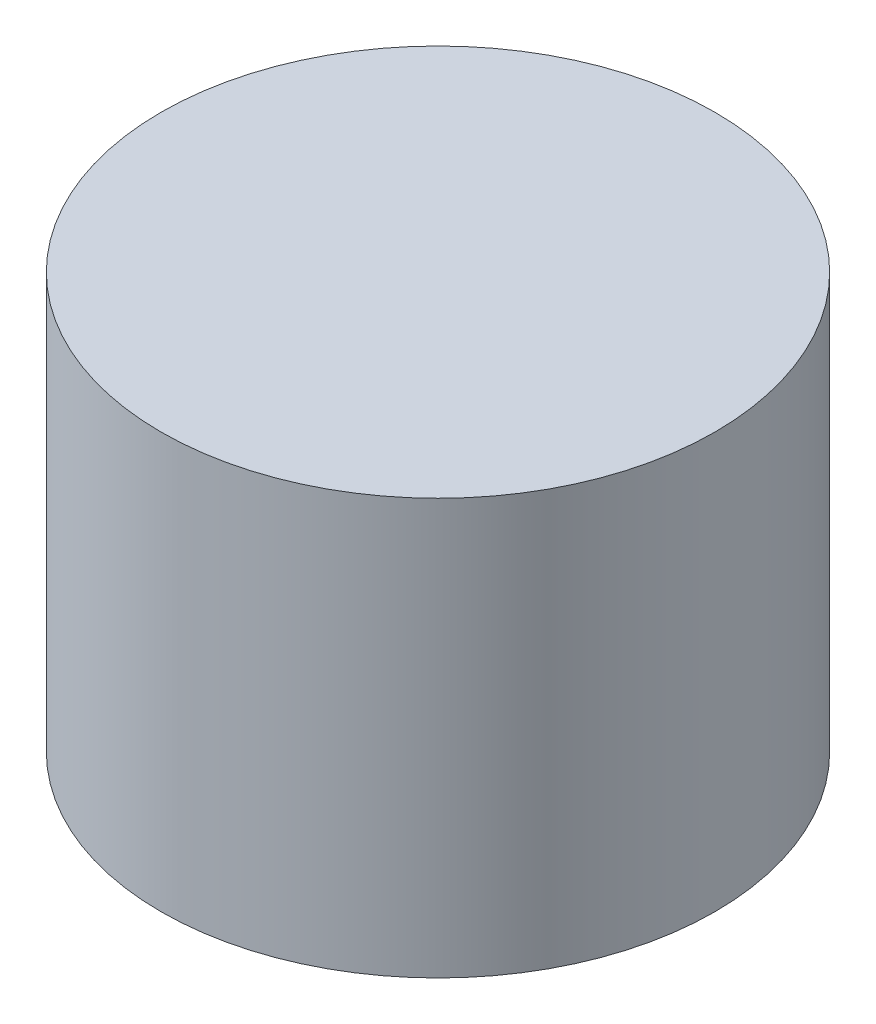
from build123d import *

# Parameters (mm, degrees)
SKETCH1_R           = 40
BOSS_EXTRUDE1_DEPTH = 60


with BuildPart() as part:
    # Sketch1 → Boss-Extrude1 (new body)
    with BuildSketch(Plane(origin=(0, 0, 0), x_dir=(1, 0, 0), z_dir=(0, 1, 0))):
        Circle(SKETCH1_R)
    extrude(amount=BOSS_EXTRUDE1_DEPTH)


solid = part.part
